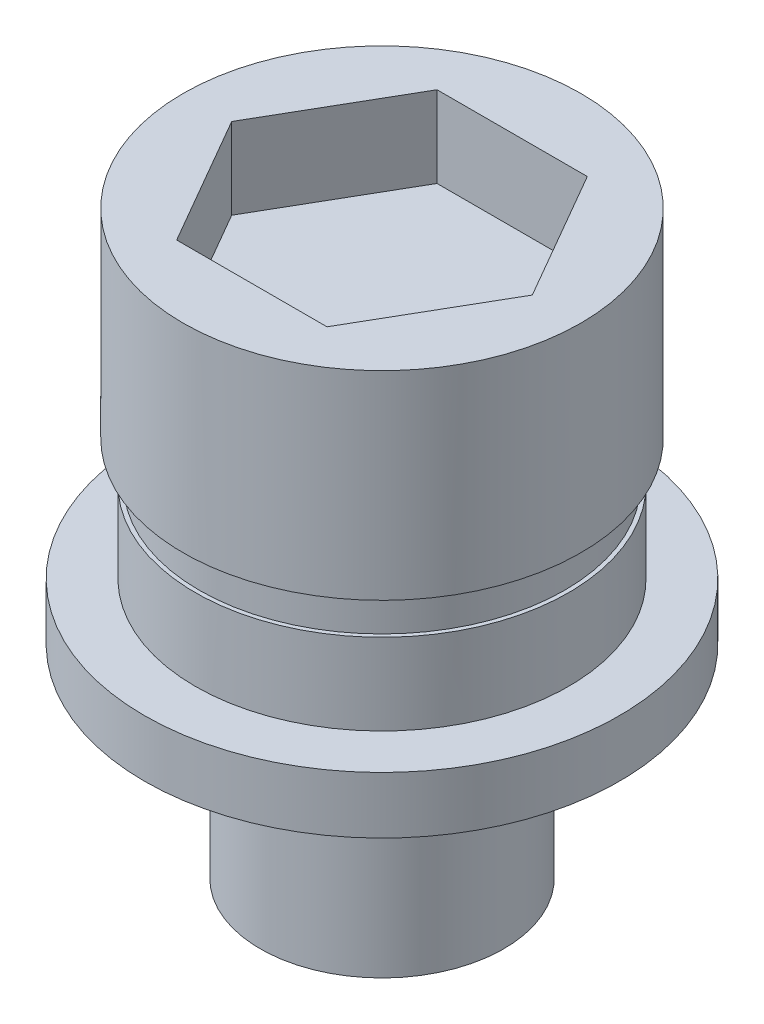
from build123d import *

# Parameters (mm, degrees)
SKETCH_1_R          = 5.85
EXTRUDE_1_DEPTH     = 1.4
SKETCH_2_R          = 4.6
EXTRUDE_2_DEPTH     = 2
SKETCH_3_R          = 4.9
EXTRUDE_3_DEPTH     = 5.9
SKETCH_4_R          = 10.526345736
SKETCH_4_R_2        = 4.5
CUT_EXTRUDE_1_DEPTH = 1
CUT_EXTRUDE_2_DEPTH = 2
SKETCH_6_R          = 3
EXTRUDE_4_DEPTH     = 5


with BuildPart() as part:
    # 草图1 → 凸台-拉伸1 (new body)
    with BuildSketch(Plane(origin=(0, 0, 0), x_dir=(1, 0, 0), z_dir=(0, 1, 0))):
        Circle(SKETCH_1_R)
    extrude(amount=EXTRUDE_1_DEPTH)

    # 草图2 → 凸台-拉伸2 (add)
    with BuildSketch(Plane(origin=(0, 1.4, 0), x_dir=(1, 0, 0), z_dir=(0, 1, 0))):
        Circle(SKETCH_2_R)
    extrude(amount=EXTRUDE_2_DEPTH)

    # 草图3 → 凸台-拉伸3 (add)
    with BuildSketch(Plane(origin=(0, 3.4, 0), x_dir=(1, 0, 0), z_dir=(0, 1, 0))):
        Circle(SKETCH_3_R)
    extrude(amount=EXTRUDE_3_DEPTH)

    # 草图4 → 切除-拉伸1 (cut)
    with BuildSketch(Plane.XZ.offset(-3.4)):
        Circle(SKETCH_4_R)
        Circle(SKETCH_4_R_2, mode=Mode.SUBTRACT)
    extrude(amount=-CUT_EXTRUDE_1_DEPTH, mode=Mode.SUBTRACT)

    # 草图5 → 切除-拉伸2 (cut)
    with BuildSketch(Plane(origin=(0, 9.3, 0), x_dir=(1, 0, 0), z_dir=(0, 1, 0))):
        Polygon((-3.702575932, 0), (-1.851287966, -3.206524817), (1.851287966, -3.206524817), (3.702575932, 0), (1.851287966, 3.206524817), (-1.851287966, 3.206524817), align=None)
    extrude(amount=-CUT_EXTRUDE_2_DEPTH, mode=Mode.SUBTRACT)

    # 草图6 → 凸台-拉伸4 (add)
    with BuildSketch(Plane.XZ):
        Circle(SKETCH_6_R)
    extrude(amount=EXTRUDE_4_DEPTH)


solid = part.part
